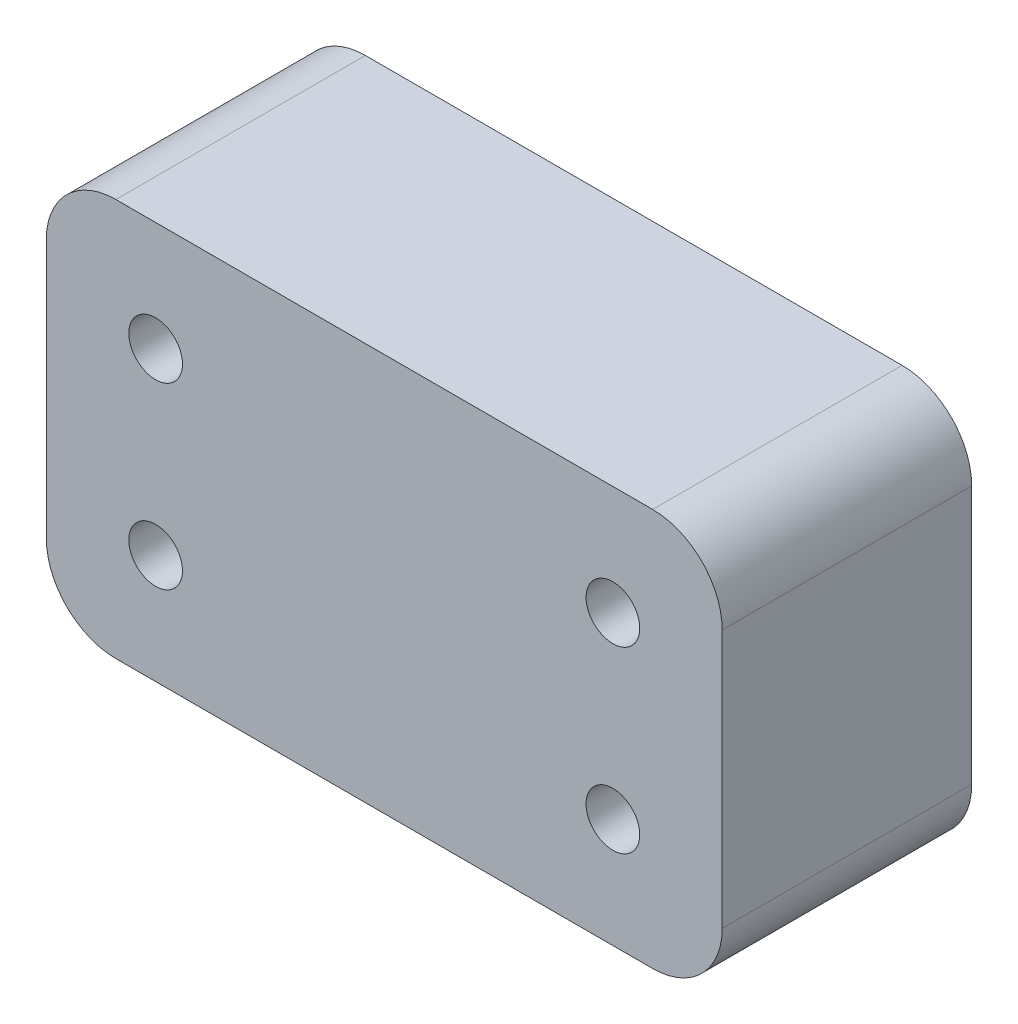
from build123d import *

# Parameters (mm, degrees)
SKETCH1_W            = 59.999999999
SKETCH1_H            = 32
BOSS_EXTRUDE1_DEPTH  = 25.1
M5_CLEARANCE_HOLE1_D = 5.4
FILLET1_R            = 3
BOSS_EXTRUDE2_DEPTH  = 25.1


with BuildPart() as part:
    # Sketch1 → Boss-Extrude1 (new body)
    with BuildSketch(Plane.XY):
        with Locations((8.905545777, 63)):
            Rectangle(SKETCH1_W, SKETCH1_H)
    extrude(amount=BOSS_EXTRUDE1_DEPTH)

    # M5 Clearance Hole1 (through all)
    with Locations(Plane(origin=(0, 0, 25.1), x_dir=(-1, 0, 0), z_dir=(0, 0, 1))):
        with Locations((-31.905545776, -72), (-31.905545776, -54), (14.094454224, -54), (14.094454224, -72)):
            Hole(M5_CLEARANCE_HOLE1_D / 2)

    # Fillet1
    fillet1_edges = [part.edges().sort_by_distance(p)[0] for p in [
        (-21.094454223, 47, 12.55),
        (-21.094454223, 79, 12.55),
        (38.905545776, 79, 12.55),
        (38.905545776, 47, 12.55),
    ]]
    fillet(fillet1_edges, radius=FILLET1_R)

    # Sketch4 → Boss-Extrude2 (add)
    with BuildSketch(Plane.XY.offset(25.1)):
        with BuildLine():
            Line((42.905545776, 50), (42.905545776, 76))
            ThreePointArc((42.905545776, 76), (40.855293244, 80.949747468), (35.905545776, 83))
            Line((35.905545776, 83), (-18.094454223, 83))
            ThreePointArc((-18.094454223, 83), (-23.044201691, 80.949747468), (-25.094454223, 76))
            Line((-25.094454223, 76), (-25.094454223, 50))
            ThreePointArc((-25.094454223, 50), (-23.044201691, 45.050252532), (-18.094454223, 43))
            Line((-18.094454223, 43), (35.905545776, 43))
            ThreePointArc((35.905545776, 43), (40.855293244, 45.050252532), (42.905545776, 50))
        make_face()
        with BuildLine():
            Line((35.905545776, 79), (-18.094454223, 79))
            ThreePointArc((-18.094454223, 79), (-20.215774567, 78.121320343), (-21.094454223, 76))
            Line((-21.094454223, 76), (-21.094454223, 50))
            ThreePointArc((-21.094454223, 50), (-20.215774567, 47.878679656), (-18.094454223, 47))
            Line((-18.094454223, 47), (35.905545776, 47))
            ThreePointArc((35.905545776, 47), (38.026866119, 47.878679656), (38.905545776, 50))
            Line((38.905545776, 50), (38.905545776, 76))
            ThreePointArc((38.905545776, 76), (38.026866119, 78.121320343), (35.905545776, 79))
        make_face(mode=Mode.SUBTRACT)
    extrude(amount=-BOSS_EXTRUDE2_DEPTH)


solid = part.part
